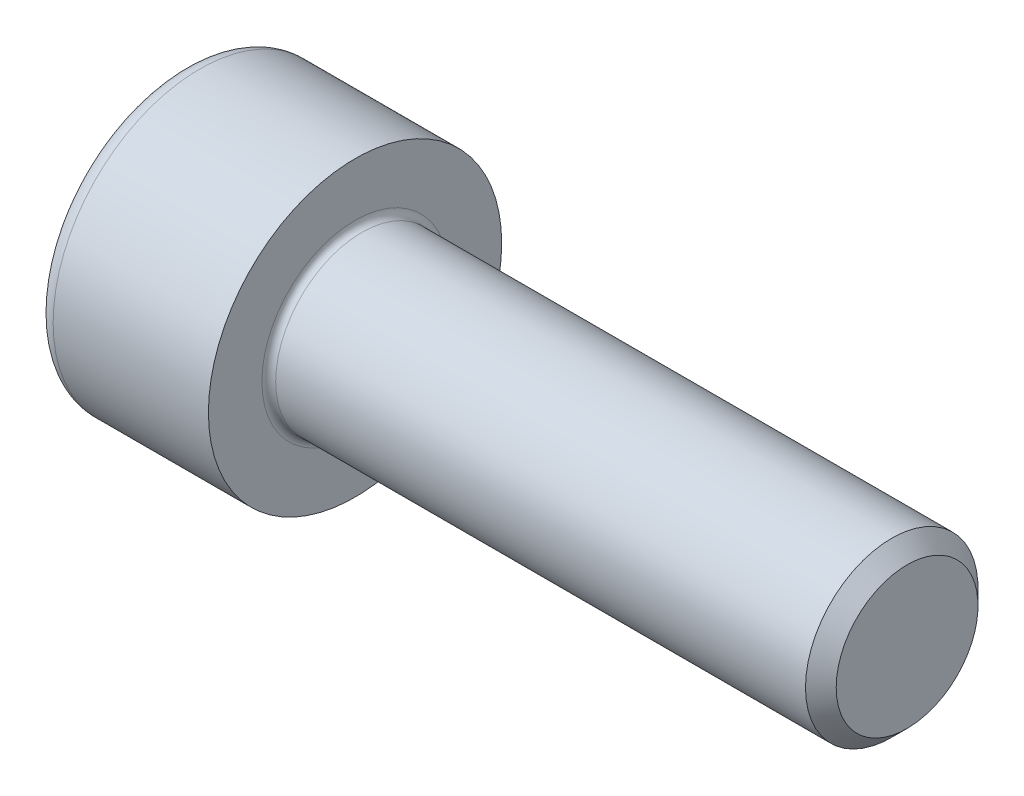
from build123d import *

# Parameters (mm, degrees)
FILLET1_R   = 0.2
FILLET2_R   = 0.5
HEX_2_DEPTH = 2.5


with BuildPart() as part:
    # BodySke → Base-Revolve (revolve)
    with BuildSketch(Plane.XY):
        Polygon((0, 0), (0, 4.25), (5, 4.25), (5, 2.5), (20.555, 2.5), (21, 2.055), (21, 0), align=None)
    revolve(axis=Axis((-31.75, 0, 0), (1, 0, 0)))

    # Fillet1
    fillet1_edges = [part.edges().sort_by_distance(p)[0] for p in [
        (5, -2.5, 0),
    ]]
    fillet(fillet1_edges, radius=FILLET1_R)

    # Fillet2
    fillet2_edges = [part.edges().sort_by_distance(p)[0] for p in [
        (0, -4.25, 0),
    ]]
    fillet(fillet2_edges, radius=FILLET2_R)

    # Sketch2 → Hex-PreBroach (revolve, cut)
    with BuildSketch(Plane.XY):
        Polygon((0, 2.01), (2.5, 2.01), (3.660474041, 0), (0, 0), align=None)
    revolve(axis=Axis((0, 0, 0), (1, 0, 0)), mode=Mode.SUBTRACT)

    # Sketch3 → Hex 2 (cut)
    with BuildSketch(Plane(origin=(0, 0, 0), x_dir=(0, 0.5, 0.866025404), z_dir=(-1, 0, 0))):
        Polygon((1.160474041, 2.01), (-1.160474041, 2.01), (-2.320948082, 0), (-1.160474041, -2.01), (1.160474041, -2.01), (2.320948082, 0), align=None)
    extrude(amount=-HEX_2_DEPTH, mode=Mode.SUBTRACT)


solid = part.part
